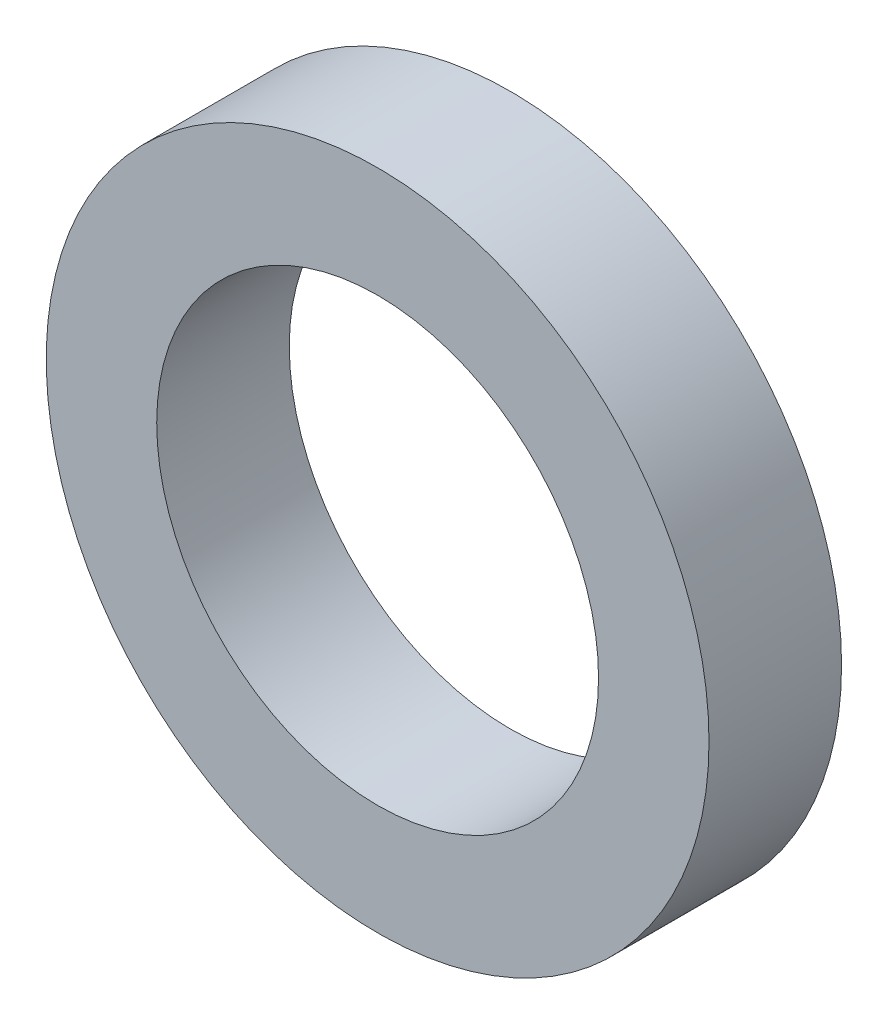
from build123d import *

# Parameters (mm, degrees)
SKETCH1_R           = 7.5
SKETCH1_R_2         = 5
BOSS_EXTRUDE1_DEPTH = 3


with BuildPart() as part:
    # Sketch1 → Boss-Extrude1 (new body)
    with BuildSketch(Plane.XY):
        Circle(SKETCH1_R)
        Circle(SKETCH1_R_2, mode=Mode.SUBTRACT)
    extrude(amount=BOSS_EXTRUDE1_DEPTH)


solid = part.part
